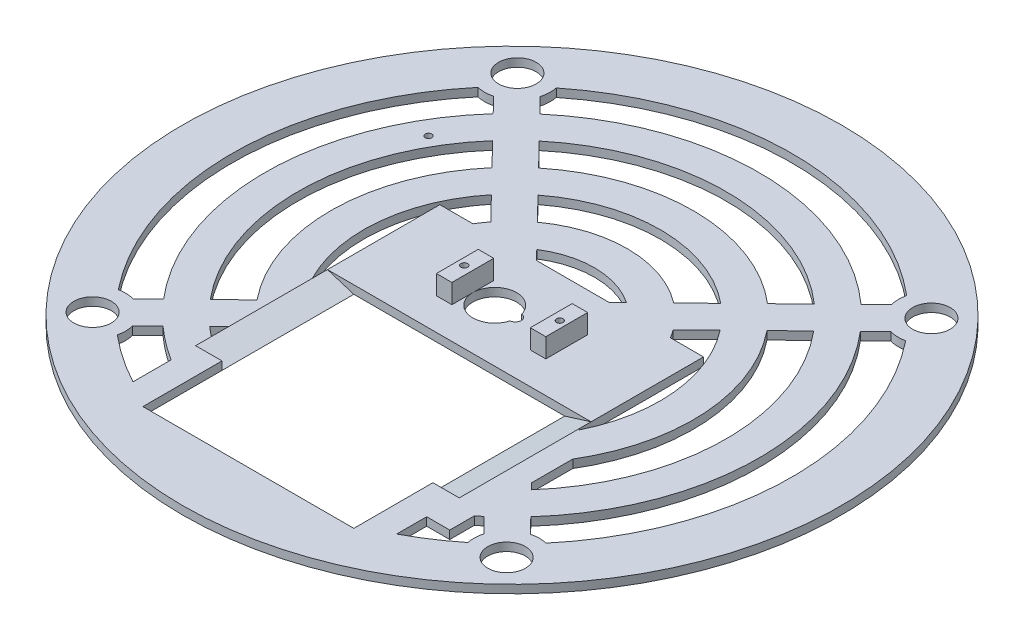
from build123d import *

# Parameters (mm, degrees)
IZIM1_R                     = 100
IZIM1_W                     = 64
IZIM1_H                     = 64
Y_KSEKLIK_EKSTR_ZYON1_DEPTH = 2.5
KES_EKSTR_ZYON1_DEPTH       = 142.443451598
IZIM3_W                     = 4.7
IZIM3_H                     = 12.7
IZIM3_R                     = 1
Y_KSEKLIK_EKSTR_ZYON2_DEPTH = 5.85
IZIM4_W                     = 4
IZIM4_H                     = 30
Y_KSEKLIK_EKSTR_ZYON3_DEPTH = 4
Y_KSEKLIK_EKSTR_ZYON4_START = 4
IZIM4_3_W                   = 3
IZIM4_3_H                   = 30
IZIM4_3_W_2                 = 4
Y_KSEKLIK_EKSTR_ZYON4_DEPTH = 3
IZIM5_R                     = 3
Y_KSEKLIK_EKSTR_ZYON5_DEPTH = 3
Y_KSEKLIK_EKSTR_ZYON6_START = 3
IZIM5_3_R                   = 5
Y_KSEKLIK_EKSTR_ZYON6_DEPTH = 2
IZIM11_R                    = 1
KES_EKSTR_ZYON5_DEPTH       = 142.667648036
IZIM12_R                    = 5.7
KES_EKSTR_ZYON6_DEPTH       = 142.667648036
KES_EKSTR_ZYON7_DEPTH       = 142.740079018
KES_EKSTR_ZYON8_DEPTH       = 40


with BuildPart() as part:
    # Çizim1 → Yükseklik-Ekstrüzyon1 (new body)
    with BuildSketch(Plane(origin=(0, 0, 0), x_dir=(1, 0, 0), z_dir=(0, 1, 0))):
        with Locations(Location((0, 0, 0), (0, 0, 270))):
            Circle(IZIM1_R)
        with Locations((0, -48)):
            Rectangle(IZIM1_W, IZIM1_H, mode=Mode.SUBTRACT)
    extrude(amount=Y_KSEKLIK_EKSTR_ZYON1_DEPTH)

    # Çizim2 → Kes-Ekstrüzyon1 (cut, through all)
    with BuildSketch(Plane.XZ):
        with BuildLine():
            ThreePointArc((1.17075, 1.767705982), (-11.89, 0), (1.17075, -1.767705982))
            ThreePointArc((1.17075, -1.767705982), (2.785, 0), (1.17075, 1.767705982))
        make_face()
        with BuildLine():
            ThreePointArc((0.78075, 1.254220649), (-11.39, 0), (0.78075, -1.254220649))
            ThreePointArc((0.78075, -1.254220649), (2.285, 0), (0.78075, 1.254220649))
        make_face(mode=Mode.SUBTRACT)
        with BuildLine():
            ThreePointArc((0.78075, -1.254220649), (2.285, 0), (0.78075, 1.254220649))
            ThreePointArc((0.78075, 1.254220649), (-11.39, 0), (0.78075, -1.254220649))
        make_face()
    extrude(amount=-KES_EKSTR_ZYON1_DEPTH, mode=Mode.SUBTRACT)

    # Çizim3 → Yükseklik-Ekstrüzyon2 (add)
    with BuildSketch(Plane(origin=(0, 2.5, 0), x_dir=(1, 0, 0), z_dir=(0, 1, 0))):
        with Locations((-14.24, 0)):
            Rectangle(IZIM3_W, IZIM3_H)
        with Locations((-14.49, 0)):
            Circle(IZIM3_R, mode=Mode.SUBTRACT)
        with Locations((14.26, 0)):
            Rectangle(IZIM3_W, IZIM3_H)
        with Locations((14.51, 0)):
            Circle(IZIM3_R, mode=Mode.SUBTRACT)
    extrude(amount=Y_KSEKLIK_EKSTR_ZYON2_DEPTH)

    # Çizim4 → Yükseklik-Ekstrüzyon3 (add)
    with BuildSketch(Plane.XZ):
        with Locations((37, 42.891487162)):
            Rectangle(IZIM4_W, IZIM4_H)
    extrude(amount=Y_KSEKLIK_EKSTR_ZYON3_DEPTH)

    # Çizim4<3> → Yükseklik-Ekstrüzyon4 (add)
    with BuildSketch(Plane.XZ.offset(Y_KSEKLIK_EKSTR_ZYON4_START)):
        with Locations((33.5, 42.891487162)):
            Rectangle(IZIM4_3_W, IZIM4_3_H)
        with Locations((37, 42.891487162)):
            Rectangle(IZIM4_3_W_2, IZIM4_3_H)
    extrude(amount=Y_KSEKLIK_EKSTR_ZYON4_DEPTH)

    # Çizim5 → Yükseklik-Ekstrüzyon5 (add)
    with BuildSketch(Plane.XZ):
        with Locations(Location((-21.143733637, -10.434588388, 0), (0, 0, 90))):
            Circle(IZIM5_R)
    extrude(amount=Y_KSEKLIK_EKSTR_ZYON5_DEPTH)

    # Çizim5<3> → Yükseklik-Ekstrüzyon6 (add)
    with BuildSketch(Plane.XZ.offset(Y_KSEKLIK_EKSTR_ZYON6_START)):
        with Locations(Location((-21.143733637, -10.434588388, 0), (0, 0, 270))):
            Circle(IZIM5_3_R)
    extrude(amount=Y_KSEKLIK_EKSTR_ZYON6_DEPTH)

    # Çizim11 → Kes-Ekstrüzyon5 (cut, through all)
    with BuildSketch(Plane.XZ):
        with Locations(Location((-59.798043504, -34.469478679, 0), (0, 0, 270))):
            Circle(IZIM11_R)
    extrude(amount=-KES_EKSTR_ZYON5_DEPTH, mode=Mode.SUBTRACT)

    # Çizim12 → Kes-Ekstrüzyon6 (cut, through all)
    with BuildSketch(Plane.XZ):
        with Locations(Location((-64.455689055, 62.812929787, 0), (0, 0, 270))):
            Circle(IZIM12_R)
        with Locations(Location((62.812929787, 64.455689055, 0), (0, 0, 270))):
            Circle(IZIM12_R)
        with Locations(Location((64.455689055, -62.812929787, 0), (0, 0, 270))):
            Circle(IZIM12_R)
        with Locations(Location((-62.812929787, -64.455689055, 0), (0, 0, 270))):
            Circle(IZIM12_R)
    extrude(amount=-KES_EKSTR_ZYON6_DEPTH, mode=Mode.SUBTRACT)

    # Çizim13 → Kes-Ekstrüzyon7 (cut, through all)
    with BuildSketch(Plane(origin=(0, 2.5, 0), x_dir=(1, 0, 0), z_dir=(0, 1, 0))):
        with BuildLine():
            Line((49.903008022, 41.649607326), (42.716090382, 34.645860105))
            ThreePointArc((42.716090382, 34.645860105), (51.838137365, 18.379540649), (55, 0))
            ThreePointArc((55, 0), (52.962250707, -14.832396974), (47, -28.565713714))
            Line((47, -28.565713714), (47, -41.065070429))
            Line((47, -41.065070429), (48.811350554, -42.923793601))
            ThreePointArc((48.811350554, -42.923793601), (60.81832695, -22.937547973), (65, 0))
            ThreePointArc((65, 0), (61.109309935, 22.150671306), (49.903008022, 41.649607326))
        make_face()
        with BuildLine():
            Line((35.517896602, 27.631124135), (28.298613495, 20.595836333))
            ThreePointArc((28.298613495, 20.595836333), (29.153169835, 19.367309792), (29.954428374, 18.10337595))
            Line((29.954428374, 18.10337595), (40, 18.10337595))
            Line((40, 18.10337595), (40, -19.891487162))
            Line((40, -19.891487162), (40.364944426, -19.891487162))
            ThreePointArc((40.364944426, -19.891487162), (43.825919837, -10.212186368), (45, 0))
            ThreePointArc((45, 0), (42.563513407, 14.606413881), (35.517896602, 27.631124135))
        make_face()
        with BuildLine():
            Line((61.743044694, 53.187881186), (57.083186115, 48.646786769))
            ThreePointArc((57.083186115, 48.646786769), (70.37840208, 25.920658184), (75, 0))
            ThreePointArc((75, 0), (70.037988798, -26.826854551), (55.808529997, -50.103971694))
            Line((55.808529997, -50.103971694), (60.349624415, -54.763830273))
            ThreePointArc((60.349624415, -54.763830273), (62.697904283, -54.45635062), (65.052635888, -54.709730067))
            ThreePointArc((65.052635888, -54.709730067), (79.85760468, -29.116369533), (85, 0))
            ThreePointArc((85, 0), (80.226750198, 28.083243272), (66.443092878, 53.012408064))
            ThreePointArc((66.443092878, 53.012408064), (64.082605735, 52.819891769), (61.743044694, 53.187881186))
        make_face()
        with BuildLine():
            Line((-53.187881186, 61.743044694), (-48.646786769, 57.083186115))
            ThreePointArc((-48.646786769, 57.083186115), (0.968005182, 74.993752846), (50.103971694, 55.808529997))
            Line((50.103971694, 55.808529997), (54.763830273, 60.349624415))
            ThreePointArc((54.763830273, 60.349624415), (54.45635062, 62.697904283), (54.709730067, 65.052635888))
            ThreePointArc((54.709730067, 65.052635888), (1.097072539, 84.992919892), (-53.012408064, 66.443092878))
            ThreePointArc((-53.012408064, 66.443092878), (-52.862924329, 65.454383896), (-52.812929787, 64.455689055))
            ThreePointArc((-52.812929787, 64.455689055), (-52.907111143, 63.086471397), (-53.187881186, 61.743044694))
        make_face()
        with BuildLine():
            Line((-41.649607326, 49.903008022), (-34.645860105, 42.716090382))
            ThreePointArc((-34.645860105, 42.716090382), (0.709870466, 54.995418754), (35.736875962, 41.807603334))
            Line((35.736875962, 41.807603334), (42.923793601, 48.811350554))
            ThreePointArc((42.923793601, 48.811350554), (0.838937824, 64.9945858), (-41.649607326, 49.903008022))
        make_face()
        with BuildLine():
            Line((-27.631124135, 35.517896602), (-20.595836333, 28.298613495))
            ThreePointArc((-20.595836333, 28.298613495), (0.451735751, 34.997084662), (21.319399074, 27.757579562))
            Line((21.319399074, 27.757579562), (28.538682181, 34.792867363))
            ThreePointArc((28.538682181, 34.792867363), (0.580803109, 44.996251708), (-27.631124135, 35.517896602))
        make_face()
        with BuildLine():
            Line((-13.514642522, 21.032223789), (-10.660441189, 18.10337595))
            Line((-10.660441189, 18.10337595), (11.412707121, 18.10337595))
            Line((11.412707121, 18.10337595), (14.053009368, 20.676385751))
            ThreePointArc((14.053009368, 20.676385751), (0.322668394, 24.997917615), (-13.514642522, 21.032223789))
        make_face()
        with BuildLine():
            Line((-40, 18.10337595), (-29.954428374, 18.10337595))
            ThreePointArc((-29.954428374, 18.10337595), (-28.900772761, 19.741968844), (-27.757579562, 21.319399074))
            Line((-27.757579562, 21.319399074), (-34.792867363, 28.538682181))
            ThreePointArc((-34.792867363, 28.538682181), (-44.74960726, 4.740532682), (-40, -20.615528128))
            Line((-40, -20.615528128), (-40, 18.10337595))
        make_face()
        with BuildLine():
            Line((-49.903008022, -41.649607326), (-42.716090382, -34.645860105))
            ThreePointArc((-42.716090382, -34.645860105), (-54.995418754, 0.709870466), (-41.807603334, 35.736875962))
            Line((-41.807603334, 35.736875962), (-48.811350554, 42.923793601))
            ThreePointArc((-48.811350554, 42.923793601), (-64.9945858, 0.838937824), (-49.903008022, -41.649607326))
        make_face()
        with BuildLine():
            Line((-61.743044694, -53.187881186), (-57.083186115, -48.646786769))
            ThreePointArc((-57.083186115, -48.646786769), (-74.993752846, 0.968005182), (-55.808529997, 50.103971694))
            Line((-55.808529997, 50.103971694), (-60.349624415, 54.763830273))
            ThreePointArc((-60.349624415, 54.763830273), (-62.697904283, 54.45635062), (-65.052635888, 54.709730067))
            ThreePointArc((-65.052635888, 54.709730067), (-84.992919892, 1.097072539), (-66.443092878, -53.012408064))
            ThreePointArc((-66.443092878, -53.012408064), (-64.082605735, -52.819891769), (-61.743044694, -53.187881186))
        make_face()
        with BuildLine():
            Line((-40, -75), (-40, -63.442887702))
            ThreePointArc((-40, -63.442887702), (-45.213408223, -59.839349235), (-50.103971694, -55.808529997))
            Line((-50.103971694, -55.808529997), (-54.763830273, -60.349624415))
            ThreePointArc((-54.763830273, -60.349624415), (-54.533023389, -61.571677963), (-54.455689055, -62.812929787))
            ThreePointArc((-54.455689055, -62.812929787), (-54.519402277, -63.939963533), (-54.709730067, -65.052635888))
            ThreePointArc((-54.709730067, -65.052635888), (-47.615341599, -70.411499376), (-40, -75))
        make_face()
        with BuildLine():
            Line((-40, -51.23475383), (-40, -45.962074643))
            Line((-40, -45.962074643), (-42.923793601, -48.811350554))
            ThreePointArc((-42.923793601, -48.811350554), (-41.479598686, -50.044409207), (-40, -51.23475383))
        make_face()
        with BuildLine():
            ThreePointArc((48.646786769, -57.083186115), (47.828251585, -57.770739569), (47, -58.446556785))
            Line((47, -58.446556785), (47, -65.891487162))
            Line((47, -65.891487162), (40, -65.891487162))
            Line((40, -65.891487162), (40, -75))
            ThreePointArc((40, -75), (46.702592844, -71.020193056), (53.012408064, -66.443092878))
            ThreePointArc((53.012408064, -66.443092878), (52.819891769, -64.082605735), (53.187881186, -61.743044694))
            Line((53.187881186, -61.743044694), (48.646786769, -57.083186115))
        make_face()
    extrude(amount=-KES_EKSTR_ZYON7_DEPTH, mode=Mode.SUBTRACT)

    # Çizim14 → Kes-Ekstrüzyon8 (cut)
    with BuildSketch(Plane.XY.offset(16)):
        Polygon((-32, 0), (-32, 2.5), (-40, 2.5), align=None)
        Polygon((32, 2.5), (32, 0), (40, 2.5), align=None)
    extrude(amount=KES_EKSTR_ZYON8_DEPTH, mode=Mode.SUBTRACT)


solid = part.part
